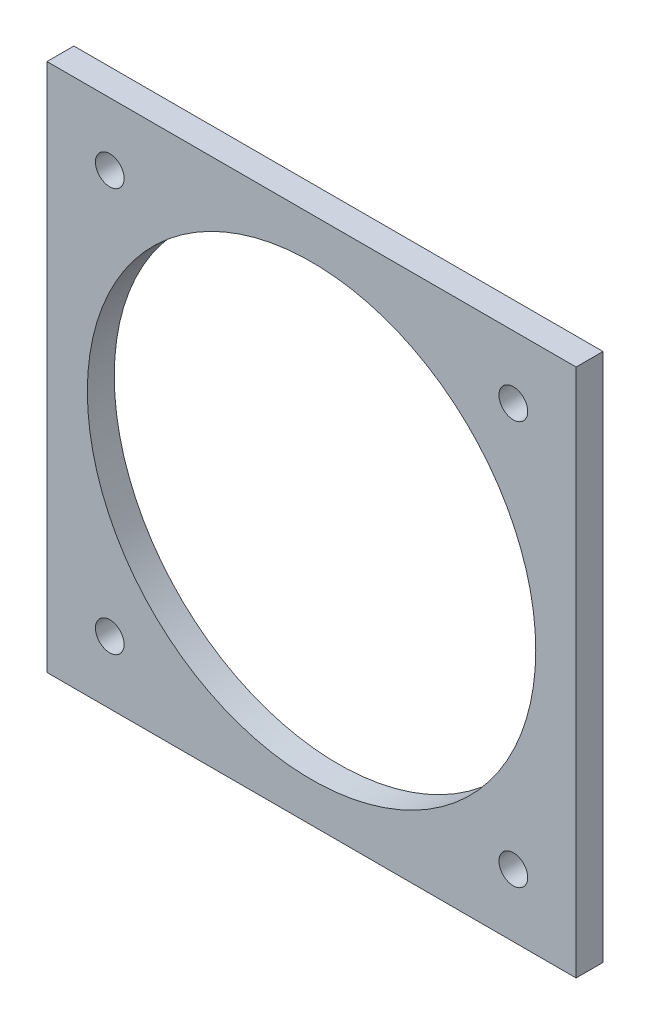
from build123d import *

# Parameters (mm, degrees)
SKIZZE1_W                       = 59
SKIZZE1_H                       = 59
SKIZZE1_R                       = 1.6
SKIZZE1_R_2                     = 25
AUFSATZ_LINEAR_AUSTRAGEN1_DEPTH = 3


with BuildPart() as part:
    # Skizze1 → Aufsatz-Linear austragen1 (new body)
    with BuildSketch(Plane.XY):
        with Locations((29.5, 29.5)):
            Rectangle(SKIZZE1_W, SKIZZE1_H)
        with Locations((7, 52)):
            Circle(SKIZZE1_R, mode=Mode.SUBTRACT)
        with Locations((52, 52)):
            Circle(SKIZZE1_R, mode=Mode.SUBTRACT)
        with Locations((52, 7)):
            Circle(SKIZZE1_R, mode=Mode.SUBTRACT)
        with Locations((7, 7)):
            Circle(SKIZZE1_R, mode=Mode.SUBTRACT)
        with Locations((29.5, 29.4)):
            Circle(SKIZZE1_R_2, mode=Mode.SUBTRACT)
    extrude(amount=AUFSATZ_LINEAR_AUSTRAGEN1_DEPTH)


solid = part.part
